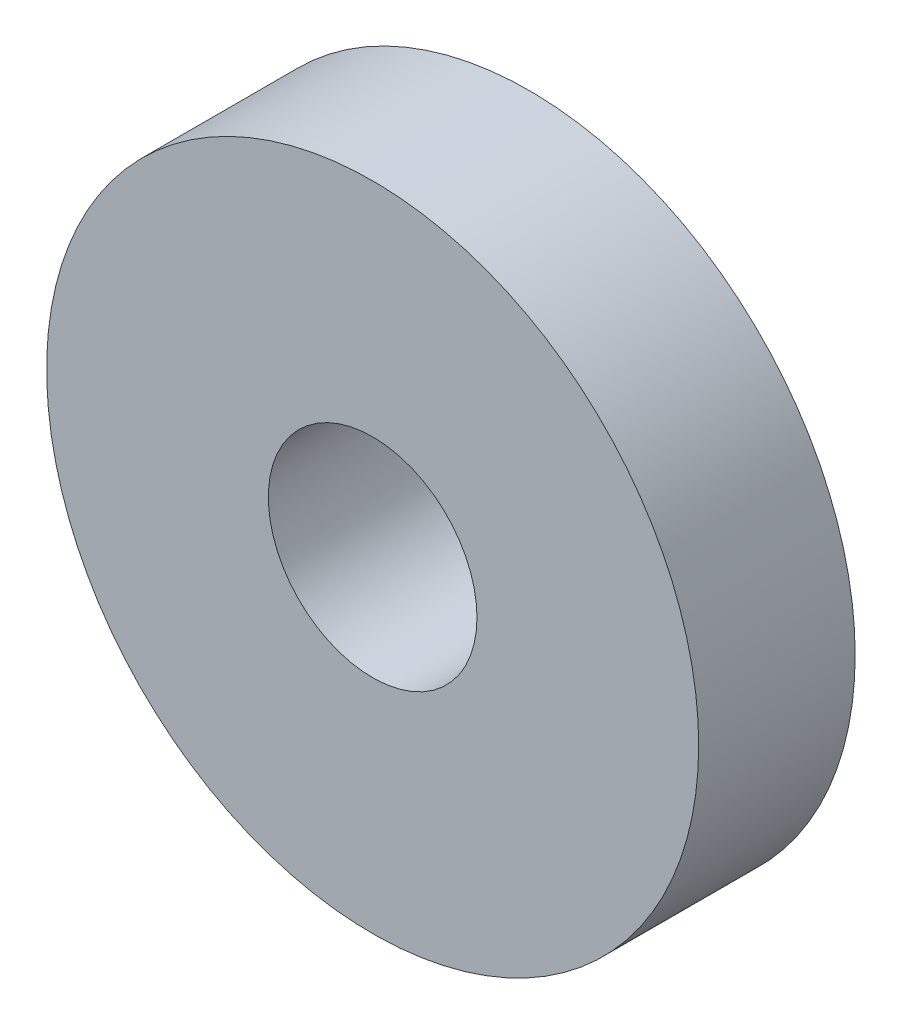
from build123d import *

# Parameters (mm, degrees)
SKETCH1_R           = 25
SKETCH1_R_2         = 8
BOSS_EXTRUDE1_DEPTH = 12


with BuildPart() as part:
    # Sketch1 → Boss-Extrude1 (new body)
    with BuildSketch(Plane.XY):
        Circle(SKETCH1_R)
        Circle(SKETCH1_R_2, mode=Mode.SUBTRACT)
    extrude(amount=BOSS_EXTRUDE1_DEPTH)


solid = part.part
